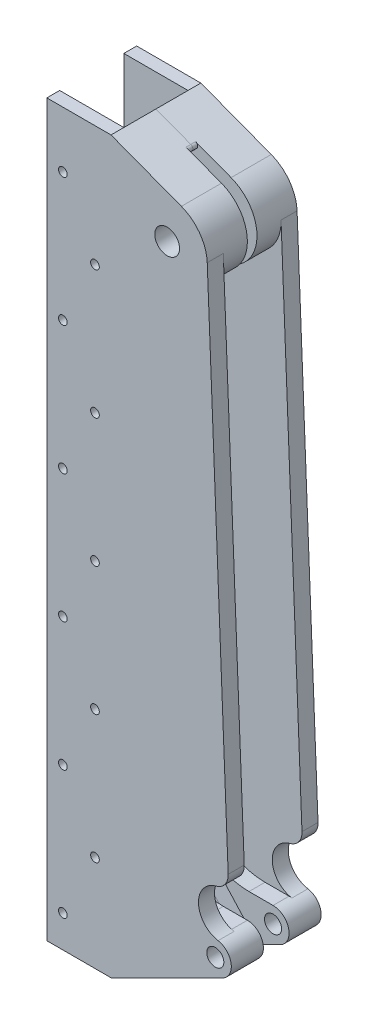
from build123d import *

# Parameters (mm, degrees)
SKETCH1_R                 = 3.3782
SKETCH1_R_2               = 4.9022
BOSS_EXTRUDE1_DEPTH       = 17.78
SKETCH2_W                 = 25.4
SKETCH2_H                 = 288.925
CUT_EXTRUDE1_DEPTH        = 12.7
SKETCH3_OUTSIDE_W         = 134.733
SKETCH3_OUTSIDE_H         = 350.633
CUT_EXTRUDE2_DEPTH        = 11.43
CUT_EXTRUDE3_DEPTH        = 5.08
SKETCH5_R                 = 19.685
CUT_EXTRUDE4_DEPTH        = 1.905
FILLET1_R                 = 1.27
F_1_8_0_135_DOWEL_HOLE1_D = 3.429
CUT_EXTRUDE6_DEPTH        = 18.7800001


with BuildPart() as part:
    # Sketch1 → Boss-Extrude1 (new body)
    with BuildSketch(Plane.XY):
        with BuildLine():
            Line((0, 0), (0, 288.925))
            Line((0, 288.925), (25.4, 288.925))
            Line((25.4, 288.925), (53.251023035, 278.369645156))
            ThreePointArc((53.251023035, 278.369645156), (60.504342029, 272.806065344), (63.48709221, 264.165043523))
            Line((63.48709221, 264.165043523), (73.019836884, 27.916617409))
            ThreePointArc((73.019836884, 27.916617409), (72.140606121, 24.428008203), (69.506926851, 21.977054424))
            Line((69.506926851, 21.977054424), (25.4, 0))
            Line((25.4, 0), (0, 0))
        make_face()
        with Locations((66.675, 27.6606)):
            Circle(SKETCH1_R, mode=Mode.SUBTRACT)
        with Locations((47.625, 263.525)):
            Circle(SKETCH1_R_2, mode=Mode.SUBTRACT)
    extrude(amount=-BOSS_EXTRUDE1_DEPTH)

    # Sketch2 → Cut-Extrude1 (cut)
    with BuildSketch(Plane(origin=(0, 0, -17.78), x_dir=(-1, 0, 0), z_dir=(0, 0, -1))):
        with Locations((-12.7, 144.4625)):
            Rectangle(SKETCH2_W, SKETCH2_H)
    extrude(amount=-CUT_EXTRUDE1_DEPTH, mode=Mode.SUBTRACT)

    # Sketch3 outside → Cut-Extrude2 (cut)
    with BuildSketch(Plane(origin=(0, 0, -17.78), x_dir=(-1, 0, 0), z_dir=(0, 0, -1))):
        with Locations((-36.5125, 144.4625)):
            Rectangle(SKETCH3_OUTSIDE_W, SKETCH3_OUTSIDE_H)
        with BuildLine():
            Line((-53.251023035, 278.369645156), (-25.4, 288.925))
            Line((-25.4, 288.925), (-25.4, 0))
            Line((-25.4, 0), (-69.506926851, 21.977054424))
            ThreePointArc((-69.506926851, 21.977054424), (-72.856141254, 29.115245248), (-66.675, 34.0106))
            Line((-66.675, 34.0106), (-57.15, 34.0106))
            ThreePointArc((-57.15, 34.0106), (-39.189487758, 41.450087758), (-31.75, 59.4106))
            Line((-31.75, 59.4106), (-31.75, 228.744617598))
            ThreePointArc((-31.75, 228.744617598), (-36.730642581, 241.588124978), (-49.068181818, 247.715735272))
            ThreePointArc((-49.068181818, 247.715735272), (-63.354239082, 261.378686208), (-53.251023035, 278.369645156))
        make_face(mode=Mode.SUBTRACT)
    extrude(amount=-CUT_EXTRUDE2_DEPTH, mode=Mode.SUBTRACT)

    # Sketch4 → Cut-Extrude3 (cut)
    with BuildSketch(Plane(origin=(0, 0, -17.78), x_dir=(-1, 0, 0), z_dir=(0, 0, -1))):
        with BuildLine():
            Line((-58.446936105, 20.191555832), (-38.342996812, 42.338499043))
            ThreePointArc((-38.342996812, 42.338499043), (-46.865821965, 36.185706413), (-57.15, 34.0106))
            Line((-57.15, 34.0106), (-75.794493201, 34.0106))
            ThreePointArc((-75.794493201, 34.0106), (-73.598883086, 18.968793556), (-58.446936105, 20.191555832))
        make_face()
    extrude(amount=-CUT_EXTRUDE3_DEPTH, mode=Mode.SUBTRACT)

    # Sketch5 → Cut-Extrude4 (cut)
    with BuildSketch(Plane(origin=(0, 0, -17.78), x_dir=(-1, 0, 0), z_dir=(0, 0, -1))):
        with Locations((-47.625, 263.525)):
            Circle(SKETCH5_R)
    extrude(amount=-CUT_EXTRUDE4_DEPTH, mode=Mode.SUBTRACT)

    # Fillet1
    fillet1_edges = [part.edges().sort_by_distance(p)[0] for p in [
        (40.904350306, 245.022781412, -16.8275),
        (42.366749421, 282.494713383, -16.8275),
        (61.344555947, 17.910009123, -15.24),
    ]]
    fillet(fillet1_edges, radius=FILLET1_R)

    # 1/8 (0.135) Dowel Hole1 (through all)
    with Locations(Plane.XY):
        with Locations((6.35, 12.7), (19.05, 38.1), (6.35, 63.5), (19.05, 88.9), (6.35, 114.3), (19.05, 139.7), (6.35, 165.1), (19.05, 190.5), (6.35, 215.9), (19.05, 241.3), (6.35, 266.7), (19.05, 292.1)):
            Hole(F_1_8_0_135_DOWEL_HOLE1_D / 2)

    # Sketch10 → Cut-Extrude6 (cut, through all)
    with BuildSketch(Plane.XY):
        with BuildLine():
            Line((73.019836884, 27.916617409), (71.779189481, 58.6633757))
            ThreePointArc((71.779189481, 58.6633757), (70.536600759, 54.627204366), (67.037279575, 52.263001115))
            ThreePointArc((67.037279575, 52.263001115), (60.019252913, 42.790446729), (67.777665928, 33.914129232))
            ThreePointArc((67.777665928, 33.914129232), (71.456094179, 31.839551836), (73.019836884, 27.916617409))
        make_face()
    extrude(amount=-CUT_EXTRUDE6_DEPTH, mode=Mode.SUBTRACT)


with BuildPart() as body_2:
    # Mirror1: mirrored copy
    add(part.part.mirror(Plane(origin=(66.675, 27.6606, -17.78), x_dir=(1, 0, 0), z_dir=(0, 0, 1))))


solid = Compound([part.part, body_2.part])
